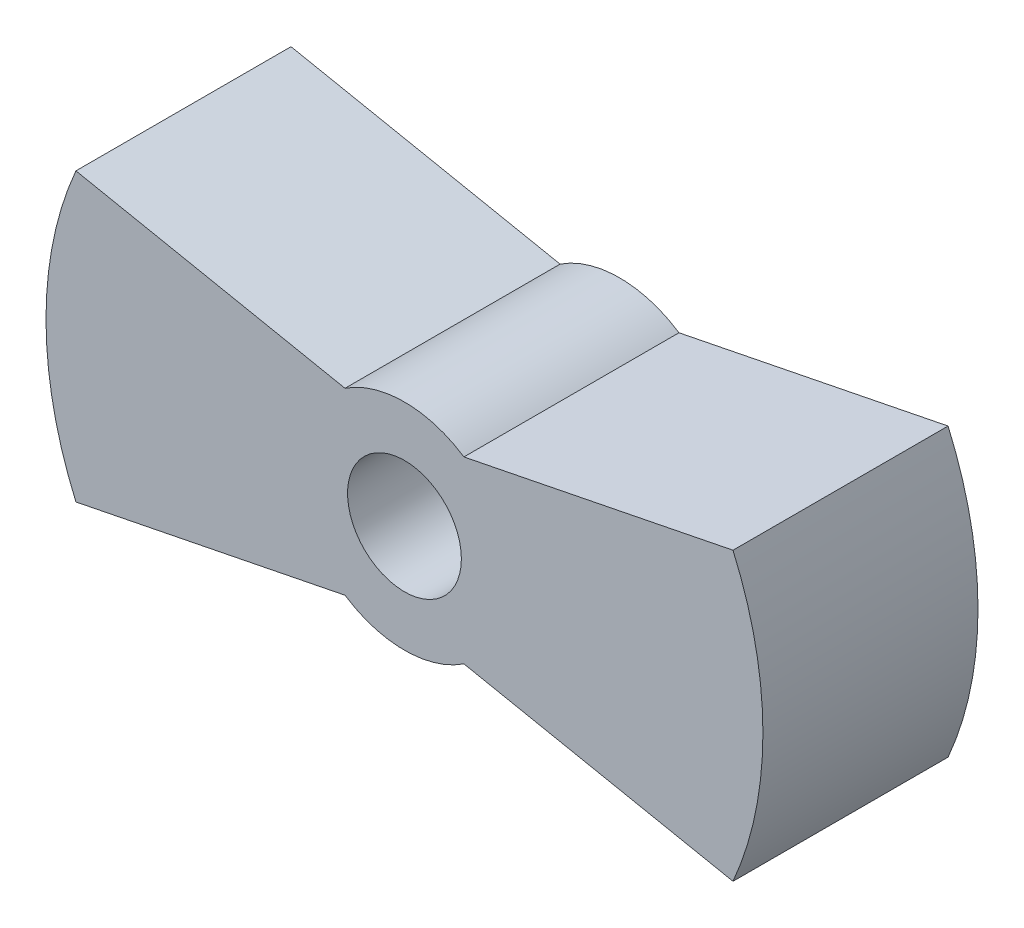
from build123d import *

# Parameters (mm, degrees)
SKETCH1_R           = 1.5875
BOSS_EXTRUDE1_DEPTH = 6
CUT_EXTRUDE1_START  = 9
CUT_EXTRUDE1_DEPTH  = 2.1


with BuildPart() as part:
    # Sketch1 → Boss-Extrude1 (new body)
    with BuildSketch(Plane.XY):
        with BuildLine():
            Line((-9.16515139, -4), (-1.658312395, -2.5))
            ThreePointArc((-1.658312395, -2.5), (0, -3), (1.658312395, -2.5))
            Line((1.658312395, -2.5), (9.16515139, -4))
            ThreePointArc((9.16515139, -4), (10, 0), (9.16515139, 4))
            Line((9.16515139, 4), (1.658312395, 2.5))
            ThreePointArc((1.658312395, 2.5), (0, 3), (-1.658312395, 2.5))
            Line((-1.658312395, 2.5), (-9.16515139, 4))
            ThreePointArc((-9.16515139, 4), (-10, 0), (-9.16515139, -4))
        make_face()
        Circle(SKETCH1_R, mode=Mode.SUBTRACT)
    extrude(amount=BOSS_EXTRUDE1_DEPTH)

    # Sketch2 → Cut-Extrude1 (cut)
    with BuildSketch(Plane(origin=(0, 0, 0), x_dir=(0, 0, -1), z_dir=(1, 0, 0)).offset(CUT_EXTRUDE1_START)):
        with BuildLine():
            Line((-3, 2.1), (-5.1, 2.1))
            Line((-5.1, 2.1), (-5.1, -2.1))
            Line((-5.1, -2.1), (-3, -2.1))
            ThreePointArc((-3, -2.1), (-0.9, 0), (-3, 2.1))
        make_face()
    cut_extrude1 = extrude(amount=-CUT_EXTRUDE1_DEPTH, mode=Mode.SUBTRACT)

    # Mirror1: Cut-Extrude1 across plane
    add(cut_extrude1.mirror(Plane(origin=(0, 0, 0), x_dir=(0, 0, 1), z_dir=(1, 0, 0))), mode=Mode.SUBTRACT)


solid = part.part
